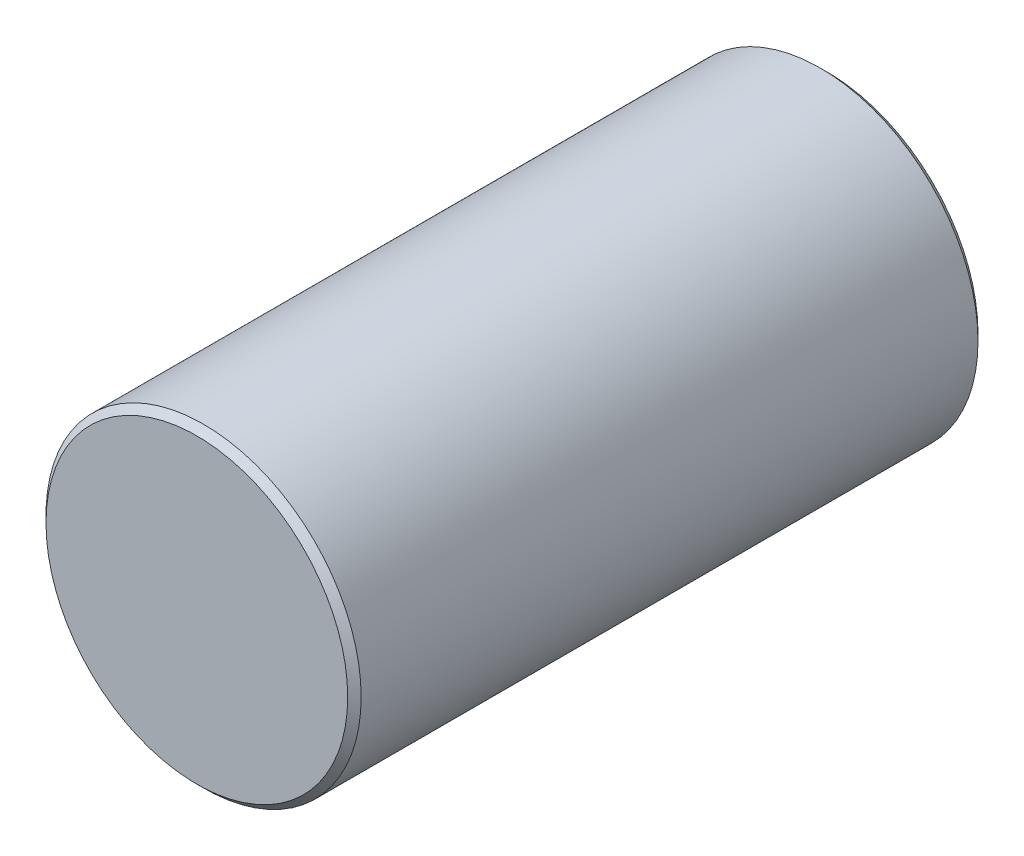
from build123d import *

# Parameters (mm, degrees)
SKETCH1_R         = 9.525
EXTRUDE1_DEPTH    = 19.05
CHAMFER1_SIZE     = 0.4064
SKETCH6_R         = 1.5875
BLIND_HOLES_DEPTH = 7.62


with BuildPart() as part:
    # Sketch1 → Extrude1 (new body, symmetric)
    with BuildSketch(Plane.XY):
        Circle(SKETCH1_R)
    extrude(amount=EXTRUDE1_DEPTH, both=True)

    # Chamfer1
    chamfer1_edges = [part.edges().sort_by_distance(p)[0] for p in [
        (-9.525, 0, -19.05),
        (-9.525, 0, 19.05),
    ]]
    chamfer(chamfer1_edges, length=CHAMFER1_SIZE)

    # Sketch6 → Blind Holes (cut)
    with BuildSketch(Plane(origin=(0, -9.525, 0), x_dir=(-1, 0, 0), z_dir=(0, 1, 0))):
        with Locations(Location((0, 12.7, 0), (0, 0, 270))):  # turned: the seam where the file's is
            Circle(SKETCH6_R)
        with Locations(Location((0, -12.7, 0), (0, 0, 270))):  # turned: the seam where the file's is
            Circle(SKETCH6_R)
    extrude(amount=BLIND_HOLES_DEPTH, mode=Mode.SUBTRACT)


solid = part.part
